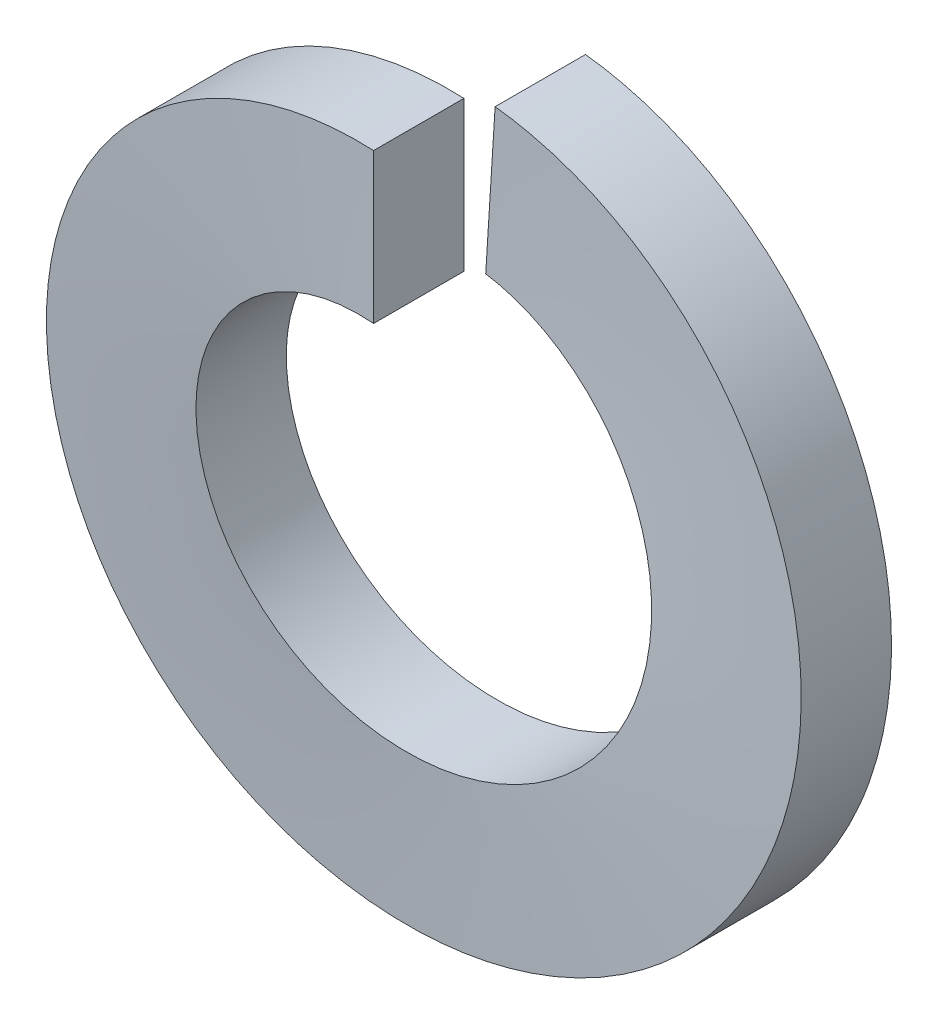
from build123d import *

# Parameters (mm, degrees)
SWEEP1_PITCH       = 2.111111111
SWEEP1_HEIGHT      = 2.09
SWEEP1_RADIUS      = 7.4
SWEEP1_START_ANGLE = 90
SKETCH2_W          = 1.9
SKETCH2_H          = 3.15


with BuildPart() as part:
    # Sweep1: sweep along a helix
    with BuildLine() as sweep1_path:
        add(Helix(SWEEP1_PITCH, SWEEP1_HEIGHT, SWEEP1_RADIUS, center=(0, 0, 0), direction=(0, 0, -1), lefthand=True, mode=Mode.PRIVATE).rotate(Axis((0, 0, 0), (0, 0, -1)), SWEEP1_START_ANGLE))
    # Sketch2 → Sweep1 (sweep)
    with BuildSketch(Plane(origin=(0, 0, 0), x_dir=(0, 0, -1), z_dir=(1, 0, 0))):
        with Locations((-0.95, 5.825)):
            Rectangle(SKETCH2_W, SKETCH2_H)
    sweep(path=sweep1_path.line, is_frenet=True)


solid = part.part
